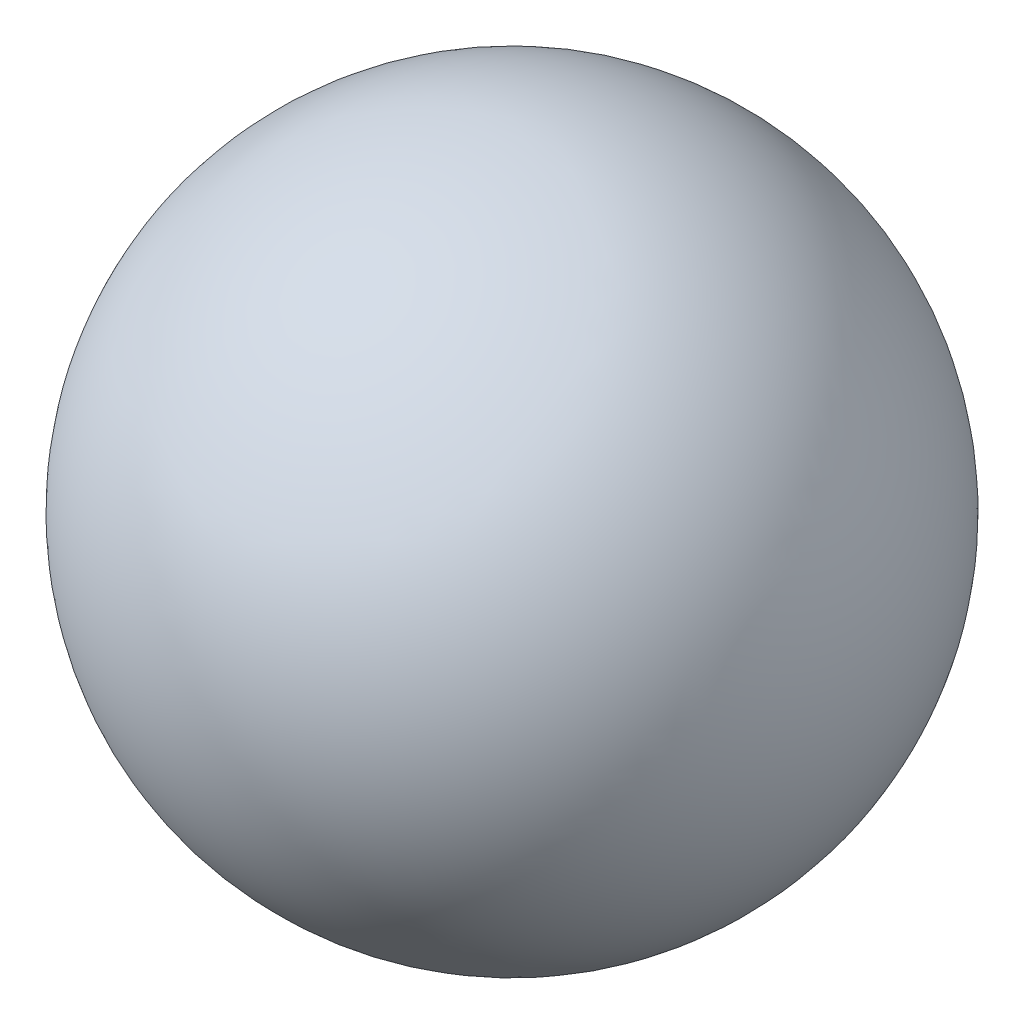
from build123d import *


with BuildPart() as part:
    # Sketch1 → Revolve1 (revolve)
    with BuildSketch(Plane(origin=(0, 0, 0), x_dir=(1, 0, 0), z_dir=(0, 1, 0))):
        with BuildLine():
            Line((-3.2, 0), (3.2, 0))
            ThreePointArc((3.2, 0), (0, 3.2), (-3.2, 0))
        make_face()
    revolve(axis=Axis((-3.2, 0, 0), (1, 0, 0)))


solid = part.part
